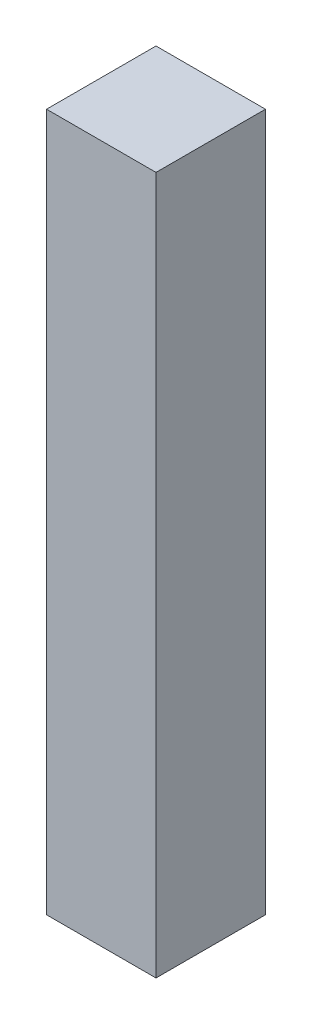
from build123d import *

# Parameters (mm, degrees)
SKETCH1_W           = 25.4
SKETCH1_H           = 25.4
BOSS_EXTRUDE1_DEPTH = 161.9


with BuildPart() as part:
    # Sketch1 → Boss-Extrude1 (new body)
    with BuildSketch(Plane(origin=(0, 0, 0), x_dir=(1, 0, 0), z_dir=(0, 1, 0))):
        Rectangle(SKETCH1_W, SKETCH1_H)
    extrude(amount=BOSS_EXTRUDE1_DEPTH)


solid = part.part
